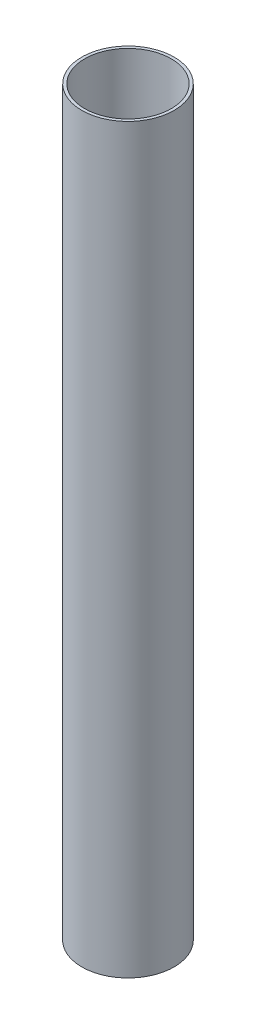
from build123d import *

# Parameters (mm, degrees)
SKETCH1_R           = 47.449994
SKETCH1_R_2         = 44.45
BOSS_EXTRUDE1_DEPTH = 762


with BuildPart() as part:
    # Sketch1 → Boss-Extrude1 (new body)
    with BuildSketch(Plane(origin=(0, 0, 0), x_dir=(1, 0, 0), z_dir=(0, 1, 0))):
        Circle(SKETCH1_R)
        Circle(SKETCH1_R_2, mode=Mode.SUBTRACT)
    extrude(amount=BOSS_EXTRUDE1_DEPTH)


solid = part.part
